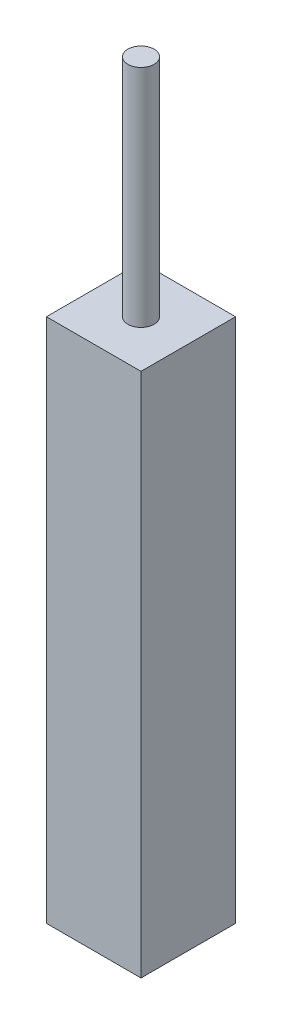
from build123d import *

# Parameters (mm, degrees)
SKETCH2_W           = 2.52
SKETCH2_H           = 2.52
BOSS_EXTRUDE1_DEPTH = 14
SKETCH3_R           = 0.35
BOSS_EXTRUDE2_DEPTH = 6


with BuildPart() as part:
    # Sketch2 → Boss-Extrude1 (new body)
    with BuildSketch(Plane(origin=(0, 0, 0), x_dir=(1, 0, 0), z_dir=(0, 1, 0))):
        with Locations((1.26, 1.26)):
            Rectangle(SKETCH2_W, SKETCH2_H)
    extrude(amount=BOSS_EXTRUDE1_DEPTH)

    # Sketch3 → Boss-Extrude2 (add)
    with BuildSketch(Plane(origin=(0, 14, 0), x_dir=(1, 0, 0), z_dir=(0, 1, 0))):
        with Locations((1.26, 1.26)):
            Circle(SKETCH3_R)
    extrude(amount=BOSS_EXTRUDE2_DEPTH)


solid = part.part
